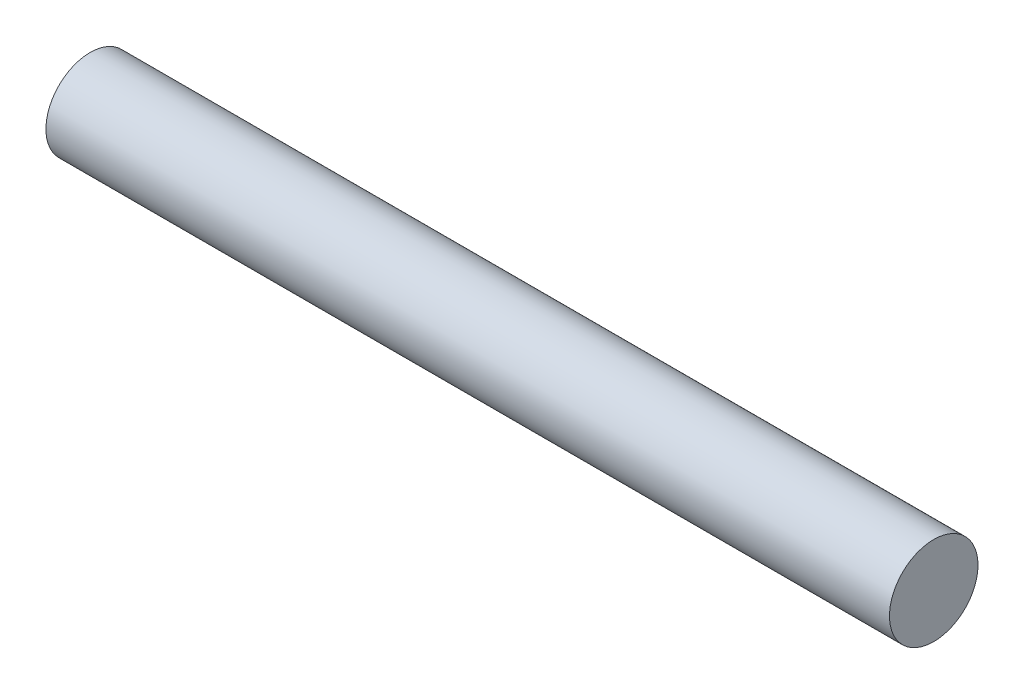
from build123d import *

# Parameters (mm, degrees)
SKETCH1_R           = 1.5875
BOSS_EXTRUDE1_DEPTH = 15.12712649


with BuildPart() as part:
    # Sketch1 → Boss-Extrude1 (new body, symmetric)
    with BuildSketch(Plane(origin=(0, 0, 0), x_dir=(0, 0, -1), z_dir=(1, 0, 0))):
        Circle(SKETCH1_R)
    extrude(amount=BOSS_EXTRUDE1_DEPTH, both=True)


solid = part.part
